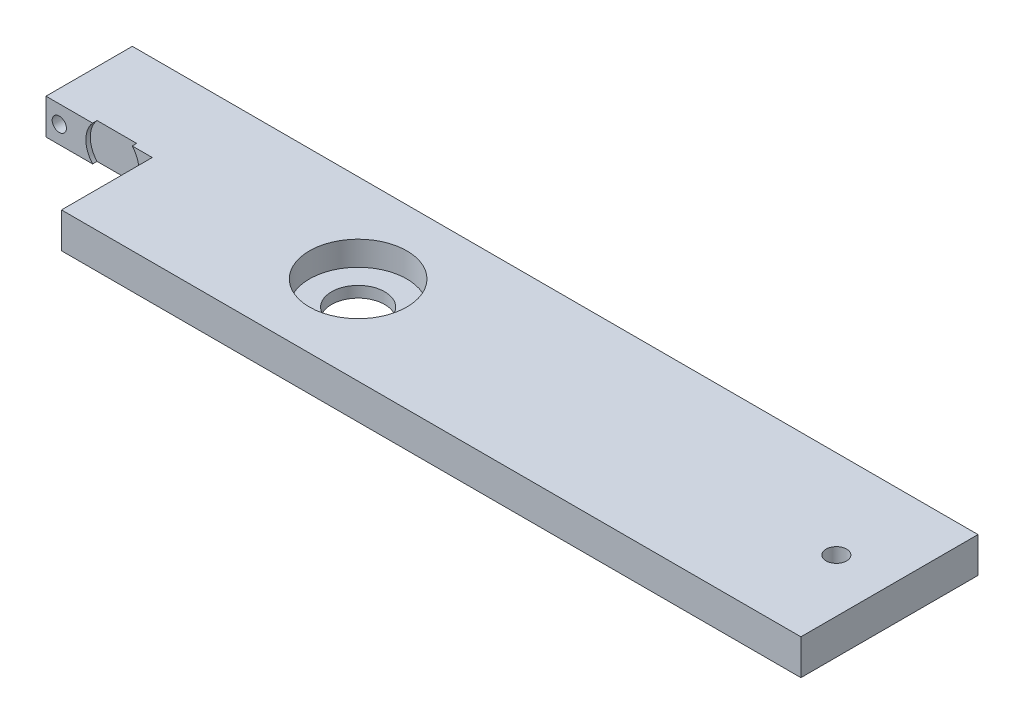
from build123d import *

# Parameters (mm, degrees)
BOSS_EXTRUDE1_DEPTH    = 12.7
SKETCH2_R              = 17.4625
CUT_EXTRUDE1_DEPTH     = 8.73125
SKETCH4_R              = 3.683
CUT_EXTRUDE3_DEPTH     = 13.7
F_10_CLEARANCE_HOLE1_D = 5.1054
SKETCH7_R              = 9.525
CUT_EXTRUDE4_DEPTH     = 1.5875
SKETCH8_R              = 9.525
CUT_EXTRUDE5_DEPTH     = 4.96875


with BuildPart() as part:
    # Sketch1 → Boss-Extrude1 (new body)
    with BuildSketch(Plane(origin=(0, 0, 0), x_dir=(1, 0, 0), z_dir=(0, 1, 0))):
        Polygon((-112.7125, 31.75), (190.5, 31.75), (190.5, -31.75), (-74.6125, -31.75), (-74.6125, 0.79375), (-76.2, 0.79375), (-112.7125, 0.79375), align=None)
    extrude(amount=BOSS_EXTRUDE1_DEPTH)

    # Sketch2 → Cut-Extrude1 (cut)
    with BuildSketch(Plane(origin=(0, 12.7, 0), x_dir=(1, 0, 0), z_dir=(0, 1, 0))):
        with Locations(Location((0, 0, 0), (0, 0, 270))):  # turned: the seam where the file's is
            Circle(SKETCH2_R)
    extrude(amount=-CUT_EXTRUDE1_DEPTH, mode=Mode.SUBTRACT)

    # Sketch4 → Cut-Extrude3 (cut, through all)
    with BuildSketch(Plane(origin=(0, 12.7, 0), x_dir=(1, 0, 0), z_dir=(0, 1, 0))):
        with Locations(Location((171.45, 0, 0), (0, 0, 270))):  # turned: the seam where the file's is
            Circle(SKETCH4_R)
    extrude(amount=-CUT_EXTRUDE3_DEPTH, mode=Mode.SUBTRACT)

    # #10 Clearance Hole1 (through all)
    with Locations(Plane(origin=(0, 0, -31.75), x_dir=(-1, 0, 0), z_dir=(0, 0, -1))):
        with Locations((107.95, 6.35)):
            Hole(F_10_CLEARANCE_HOLE1_D / 2)

    # Sketch7 → Cut-Extrude4 (cut)
    with BuildSketch(Plane.XY.offset(-0.79375)):
        with Locations((-88.9, 6.35)):
            Circle(SKETCH7_R)
    extrude(amount=-CUT_EXTRUDE4_DEPTH, mode=Mode.SUBTRACT)

    # Sketch8 → Cut-Extrude5 (cut, through all)
    with BuildSketch(Plane(origin=(0, 3.96875, 0), x_dir=(1, 0, 0), z_dir=(0, 1, 0))):
        with Locations(Location((0, 0, 0), (0, 0, 270))):  # turned: the seam where the file's is
            Circle(SKETCH8_R)
    extrude(amount=-CUT_EXTRUDE5_DEPTH, mode=Mode.SUBTRACT)


solid = part.part
